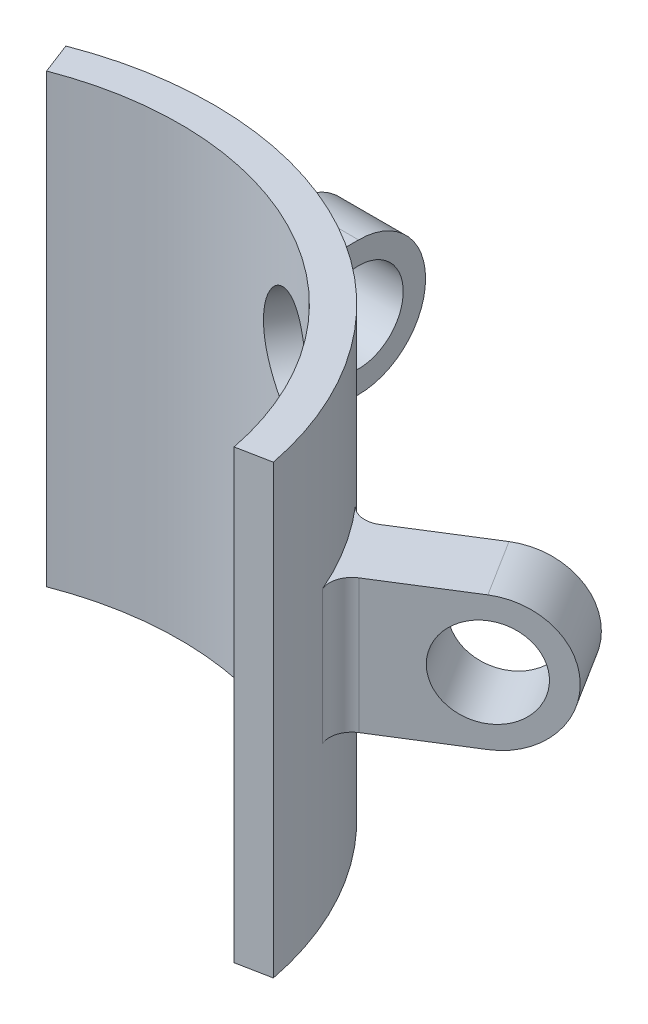
from build123d import *
from build123d.topology import SkipClean

# Parameters (mm, degrees)
SKETCH2_R               = 15.5
SKETCH2_R_2             = 14
BOSS_EXTRUDE1_DEPTH     = 20
SKETCH3_OUTSIDE_W       = 42.638
SKETCH3_OUTSIDE_H       = 42.638
CUT_EXTRUDE1_DEPTH      = 30.67322025
SKETCH6_R               = 2
BOSS_EXTRUDE2_DEPTH     = 1.5
CUT_EXTRUDE4_DEPTH      = 38.158292902
CUT_EXTRUDE4_DEPTH_BACK = 10
SKETCH9_R               = 2.5
CUT_EXTRUDE5_DEPTH      = 10
FILLET1_R               = 1


with BuildPart() as part:
    # Sketch2 → Boss-Extrude1 (new body)
    with BuildSketch(Plane(origin=(0, 0, 0), x_dir=(1, 0, 0), z_dir=(0, 1, 0))):
        Circle(SKETCH2_R)
        Circle(SKETCH2_R_2, mode=Mode.SUBTRACT)
    boss_extrude1 = extrude(amount=BOSS_EXTRUDE1_DEPTH)

    # Sketch3 outside → Cut-Extrude1 (cut, through all)
    with BuildSketch(Plane(origin=(0, 20, 0), x_dir=(1, 0, 0), z_dir=(0, 1, 0))):
        Rectangle(SKETCH3_OUTSIDE_W, SKETCH3_OUTSIDE_H)
        with BuildLine():
            Line((0, 0), (7.5, 13.564659966))
            ThreePointArc((7.5, 13.564659966), (0, 15.5), (-7.5, 13.564659966))
            Line((-7.5, 13.564659966), (0, 0))
        make_face(mode=Mode.SUBTRACT)
    extrude(amount=-CUT_EXTRUDE1_DEPTH, mode=Mode.SUBTRACT)

    # Sketch6 → Boss-Extrude2 (add, symmetric)
    with BuildSketch(Plane(origin=(0, 7.5, 0), x_dir=(0, 1, 0), z_dir=(-1, 0, 0))):
        with BuildLine():
            Line((-0.5, 20.5), (-0.5, 15.25))
            Line((-0.5, 15.25), (5.5, 15.25))
            Line((5.5, 15.25), (5.5, 20.5))
            ThreePointArc((5.5, 20.5), (2.5, 23.5), (-0.5, 20.5))
        make_face()
        with Locations((2.5, 20.5)):
            Circle(SKETCH6_R, mode=Mode.SUBTRACT)
    boss_extrude2 = extrude(amount=BOSS_EXTRUDE2_DEPTH, both=True)

    # Mirror2: Boss-Extrude1, Boss-Extrude2 across plane
    with SkipClean():  # the faces are left unmerged after this step: merging them gives an invalid solid
        add(boss_extrude1.mirror(Plane(origin=(0, 0, 0), x_dir=(-0.4838709677419353, 0, 0.8751393526613251), z_dir=(0.8751393526613249, 0, 0.48387096774193533))))
        add(boss_extrude2.mirror(Plane(origin=(0, 0, 0), x_dir=(-0.4838709677419353, 0, 0.8751393526613251), z_dir=(0.8751393526613249, 0, 0.48387096774193533))))

    # Sketch8 → Cut-Extrude4 (cut, two sides: drawn at the far end of the back side and taken through both)
    with SkipClean():  # the faces are left unmerged after this step: merging them gives an invalid solid
        with BuildSketch(Plane(origin=(0, 0, 0), x_dir=(1, 0, 0), z_dir=(0, 1, 0)).offset(-CUT_EXTRUDE4_DEPTH_BACK)):
            with BuildLine():
                Line((-5.570225317, 14.464528679), (0, 0))
                Line((0, 0), (15.212039463, 2.973862033))
                ThreePointArc((15.212039463, 2.973862033), (-7.5, -13.564659966), (-5.570225317, 14.464528679))
            make_face()
        extrude(amount=CUT_EXTRUDE4_DEPTH + CUT_EXTRUDE4_DEPTH_BACK, mode=Mode.SUBTRACT)

    # Sketch9 → Cut-Extrude5 (cut)
    with SkipClean():  # the faces are left unmerged after this step: merging them gives an invalid solid
        with BuildSketch(Plane(origin=(4.354367679, 0, -7.875402257), x_dir=(-0.875139352661325, 0, -0.4838709677419354), z_dir=(0.4838709677419354, 0, -0.875139352661325))):
            with Locations((0, 15)):
                Circle(SKETCH9_R)
            with Locations((0, 5)):
                Circle(SKETCH9_R)
        extrude(amount=CUT_EXTRUDE5_DEPTH, mode=Mode.SUBTRACT)

    # Fillet1
    fillet1_edges = [part.edges().sort_by_distance(p)[0] for p in [
        (13.863083148, 10, -6.932887251),
        (-1.5, 10, -15.427248621),
        (1.5, 10, -15.427248621),
        (12.267869828, 10, -9.473614404),
    ]]
    fillet(fillet1_edges, radius=FILLET1_R)


solid = part.part
